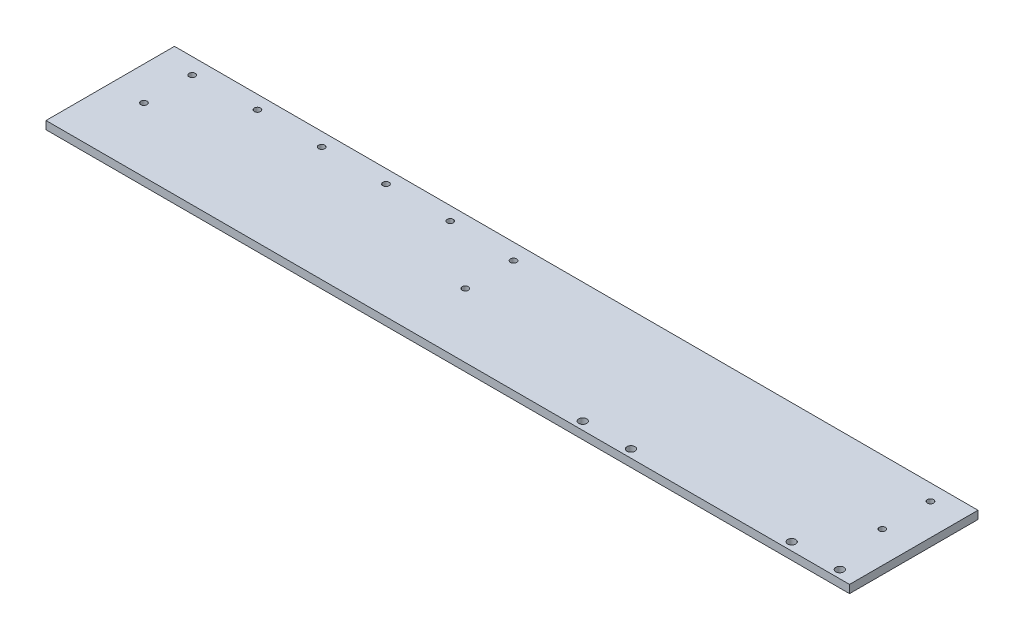
from build123d import *

# Parameters (mm, degrees)
SKETCH1_W           = 635
SKETCH1_H           = 101.527009672
SKETCH1_R           = 2.4638
SKETCH1_R_2         = 3.175
BOSS_EXTRUDE1_DEPTH = 6.35


with BuildPart() as part:
    # Sketch1 → Boss-Extrude1 (new body)
    with BuildSketch(Plane(origin=(0, 0, 0), x_dir=(1, 0, 0), z_dir=(0, 1, 0))):
        Rectangle(SKETCH1_W, SKETCH1_H)
        with Locations((-290.83, 38.063504836)):
            Circle(SKETCH1_R, mode=Mode.SUBTRACT)
        with Locations((-290.83, -0.036495164)):
            Circle(SKETCH1_R, mode=Mode.SUBTRACT)
        with Locations((292.608, 0.036495164)):
            Circle(SKETCH1_R, mode=Mode.SUBTRACT)
        with Locations((292.608, 38.063504836)):
            Circle(SKETCH1_R, mode=Mode.SUBTRACT)
        with Locations((-241.3, 40.095504834)):
            Circle(SKETCH1_R, mode=Mode.SUBTRACT)
        with Locations((-36.829999998, 38.063504838)):
            Circle(SKETCH1_R, mode=Mode.SUBTRACT)
        with Locations((-36.829999998, -0.036495162)):
            Circle(SKETCH1_R, mode=Mode.SUBTRACT)
        with Locations((100.33, -44.413504836)):
            Circle(SKETCH1_R_2, mode=Mode.SUBTRACT)
        with Locations((138.43, -44.413504836)):
            Circle(SKETCH1_R_2, mode=Mode.SUBTRACT)
        with Locations((303.53, -44.413504836)):
            Circle(SKETCH1_R_2, mode=Mode.SUBTRACT)
        with Locations((265.43, -44.413504836)):
            Circle(SKETCH1_R_2, mode=Mode.SUBTRACT)
        with Locations((-190.5, 40.095504834)):
            Circle(SKETCH1_R, mode=Mode.SUBTRACT)
        with Locations((-139.7, 40.095504834)):
            Circle(SKETCH1_R, mode=Mode.SUBTRACT)
        with Locations((-88.9, 40.095504834)):
            Circle(SKETCH1_R, mode=Mode.SUBTRACT)
    extrude(amount=BOSS_EXTRUDE1_DEPTH)


solid = part.part
